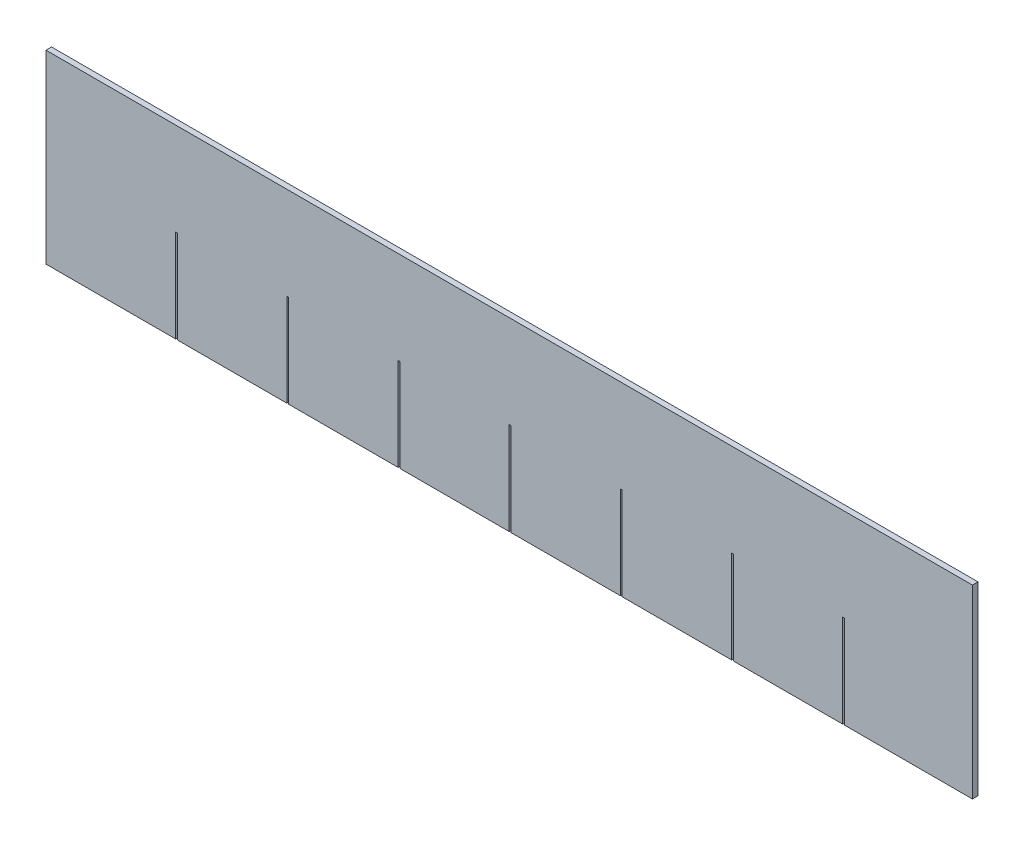
from build123d import *

# Parameters (mm, degrees)
SKETCH1_W           = 63.5
SKETCH1_H           = 12.7
BOSS_EXTRUDE1_DEPTH = 0.381
SKETCH2_W           = 0.127
SKETCH2_H           = 6.35
CUT_EXTRUDE1_DEPTH  = 1.381


with BuildPart() as part:
    # Sketch1 → Boss-Extrude1 (new body)
    with BuildSketch(Plane.XY):
        Rectangle(SKETCH1_W, SKETCH1_H)
    extrude(amount=BOSS_EXTRUDE1_DEPTH)

    # Sketch2 → Cut-Extrude1 (cut, through all)
    with BuildSketch(Plane.XY.offset(0.381)):
        with Locations((-22.7965, -3.175)):
            Rectangle(SKETCH2_W, SKETCH2_H)
        with Locations((-15.1765, -3.175)):
            Rectangle(SKETCH2_W, SKETCH2_H)
        with Locations((-7.5565, -3.175)):
            Rectangle(SKETCH2_W, SKETCH2_H)
        with Locations((0.0635, -3.175)):
            Rectangle(SKETCH2_W, SKETCH2_H)
        with Locations((7.6835, -3.175)):
            Rectangle(SKETCH2_W, SKETCH2_H)
        with Locations((15.3035, -3.175)):
            Rectangle(SKETCH2_W, SKETCH2_H)
        with Locations((22.9235, -3.175)):
            Rectangle(SKETCH2_W, SKETCH2_H)
    extrude(amount=-CUT_EXTRUDE1_DEPTH, mode=Mode.SUBTRACT)


solid = part.part
